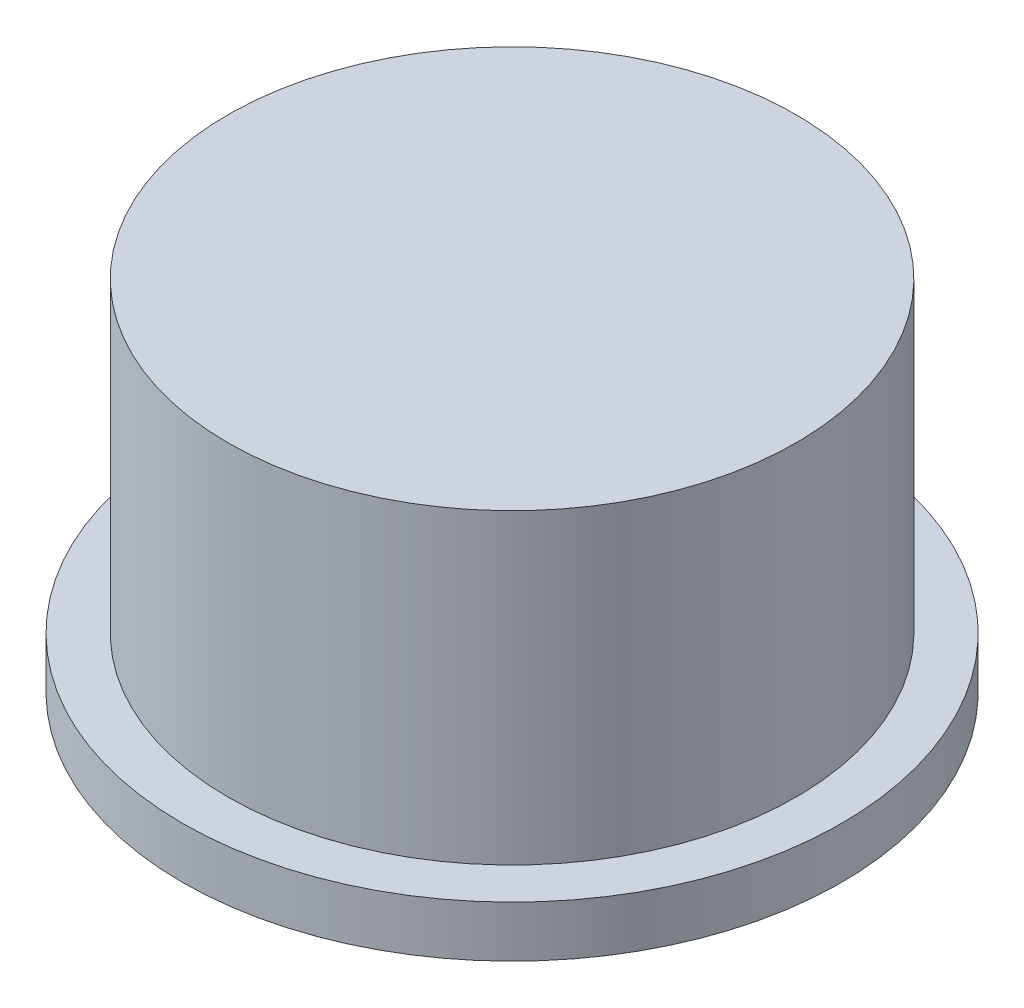
from build123d import *

# Parameters (mm, degrees)
SKETCH1_R           = 6.35
BOSS_EXTRUDE1_DEPTH = 8.001
SKETCH1_3_R         = 7.366
SKETCH1_3_R_2       = 6.35
BOSS_EXTRUDE2_DEPTH = 1.143


with BuildPart() as part:
    # Sketch1 → Boss-Extrude1 (new body)
    with BuildSketch(Plane(origin=(0, 0, 0), x_dir=(1, 0, 0), z_dir=(0, 1, 0))):
        Circle(SKETCH1_R)
    extrude(amount=BOSS_EXTRUDE1_DEPTH)

    # Sketch1_3 → Boss-Extrude2 (add)
    with BuildSketch(Plane(origin=(0, 0, 0), x_dir=(1, 0, 0), z_dir=(0, 1, 0))):
        Circle(SKETCH1_3_R)
        Circle(SKETCH1_3_R_2, mode=Mode.SUBTRACT)
    extrude(amount=BOSS_EXTRUDE2_DEPTH)

    # Sketch3 → Revolve1 (revolve)
    with BuildSketch(Plane.XY):
        with BuildLine():
            Line((0, -2), (0, 0))
            Line((0, 0), (-3.596294389, 0))
            ThreePointArc((-3.596294389, 0), (-2.057506582, -1.466366354), (0, -2))
        make_face()
    revolve(axis=Axis((0, 0, 0), (0, -1, 0)))


solid = part.part
